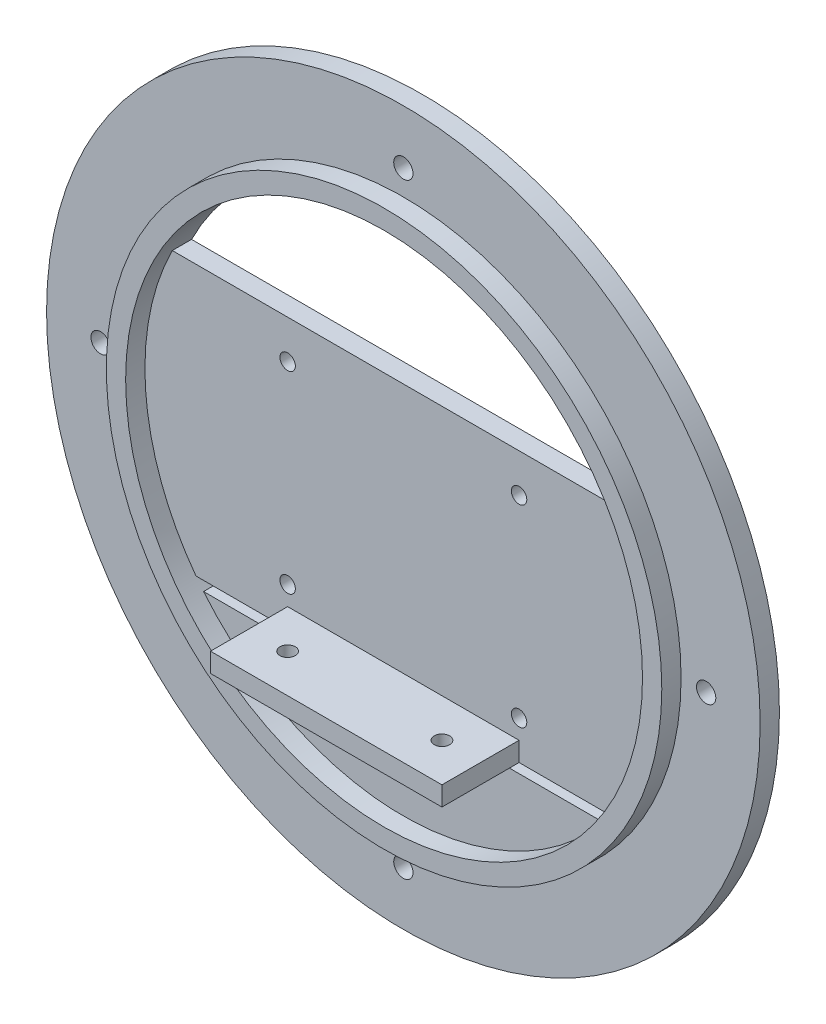
from build123d import *

# Parameters (mm, degrees)
SKETCH1_R           = 92.5
BOSS_EXTRUDE1_DEPTH = 5
SKETCH2_R           = 72
BOSS_EXTRUDE2_DEPTH = 5
SKETCH3_R           = 67
CUT_EXTRUDE1_DEPTH  = 11
SKETCH4_W           = 140
SKETCH4_H           = 70
BOSS_EXTRUDE3_DEPTH = 5
SKETCH6_W           = 60
SKETCH6_H           = 5
BOSS_EXTRUDE4_DEPTH = 20
FILLET1_R           = 2.5
SKETCH7_W           = 110
SKETCH7_H           = 25
BOSS_EXTRUDE5_DEPTH = 5
SKETCH11_R          = 2
CUT_EXTRUDE4_DEPTH  = 5
SKETCH12_R          = 2.5
CUT_EXTRUDE5_DEPTH  = 5
SKETCH13_R          = 2
CUT_EXTRUDE6_DEPTH  = 5


with BuildPart() as part:
    # Sketch1 → Boss-Extrude1 (new body)
    with BuildSketch(Plane.XY):
        Circle(SKETCH1_R)
    extrude(amount=BOSS_EXTRUDE1_DEPTH)

    # Sketch2 → Boss-Extrude2 (add)
    with BuildSketch(Plane.XY.offset(5)):
        Circle(SKETCH2_R)
    extrude(amount=BOSS_EXTRUDE2_DEPTH)

    # Sketch3 → Cut-Extrude1 (cut, through all)
    with BuildSketch(Plane(origin=(0, 0, 0), x_dir=(-1, 0, 0), z_dir=(0, 0, -1))):
        Circle(SKETCH3_R)
    extrude(amount=-CUT_EXTRUDE1_DEPTH, mode=Mode.SUBTRACT)

    # Sketch4 → Boss-Extrude3 (add)
    with BuildSketch(Plane(origin=(0, 0, 0), x_dir=(-1, 0, 0), z_dir=(0, 0, -1))):
        with Locations((0, -5)):
            Rectangle(SKETCH4_W, SKETCH4_H)
    extrude(amount=-BOSS_EXTRUDE3_DEPTH)

    # Sketch6 → Boss-Extrude4 (add)
    with BuildSketch(Plane.XY.offset(5)):
        with Locations((0, -37.5)):
            Rectangle(SKETCH6_W, SKETCH6_H)
    extrude(amount=BOSS_EXTRUDE4_DEPTH)

    # Fillet1
    fillet1_edges = [part.edges().sort_by_distance(p)[0] for p in [
        (0, -40, 0),
    ]]
    fillet(fillet1_edges, radius=FILLET1_R)

    # Sketch7 → Boss-Extrude5 (add)
    with BuildSketch(Plane(origin=(0, 0, 0), x_dir=(-1, 0, 0), z_dir=(0, 0, -1))):
        with Locations((0, -55)):
            Rectangle(SKETCH7_W, SKETCH7_H)
    extrude(amount=-BOSS_EXTRUDE5_DEPTH)

    # Sketch11 → Cut-Extrude4 (cut)
    with BuildSketch(Plane(origin=(0, 0, 0), x_dir=(-1, 0, 0), z_dir=(0, 0, -1))):
        with Locations((-30, -30)):
            Circle(SKETCH11_R)
        with Locations((-30, 20)):
            Circle(SKETCH11_R)
        with Locations((30, 20)):
            Circle(SKETCH11_R)
        with Locations((30, -30)):
            Circle(SKETCH11_R)
    extrude(amount=-CUT_EXTRUDE4_DEPTH, mode=Mode.SUBTRACT)

    # Sketch12 → Cut-Extrude5 (cut)
    with BuildSketch(Plane(origin=(0, 0, 0), x_dir=(-1, 0, 0), z_dir=(0, 0, -1))):
        with Locations((0, -78.5)):
            Circle(SKETCH12_R)
        with Locations((-78.5, 0)):
            Circle(SKETCH12_R)
        with Locations((0, 78.5)):
            Circle(SKETCH12_R)
        with Locations((78.5, 0)):
            Circle(SKETCH12_R)
    extrude(amount=-CUT_EXTRUDE5_DEPTH, mode=Mode.SUBTRACT)

    # Sketch13 → Cut-Extrude6 (cut)
    with BuildSketch(Plane(origin=(0, -35, 0), x_dir=(1, 0, 0), z_dir=(0, 1, 0))):
        with Locations((-20, -15)):
            Circle(SKETCH13_R)
        with Locations((20, -15)):
            Circle(SKETCH13_R)
    extrude(amount=-CUT_EXTRUDE6_DEPTH, mode=Mode.SUBTRACT)


solid = part.part
